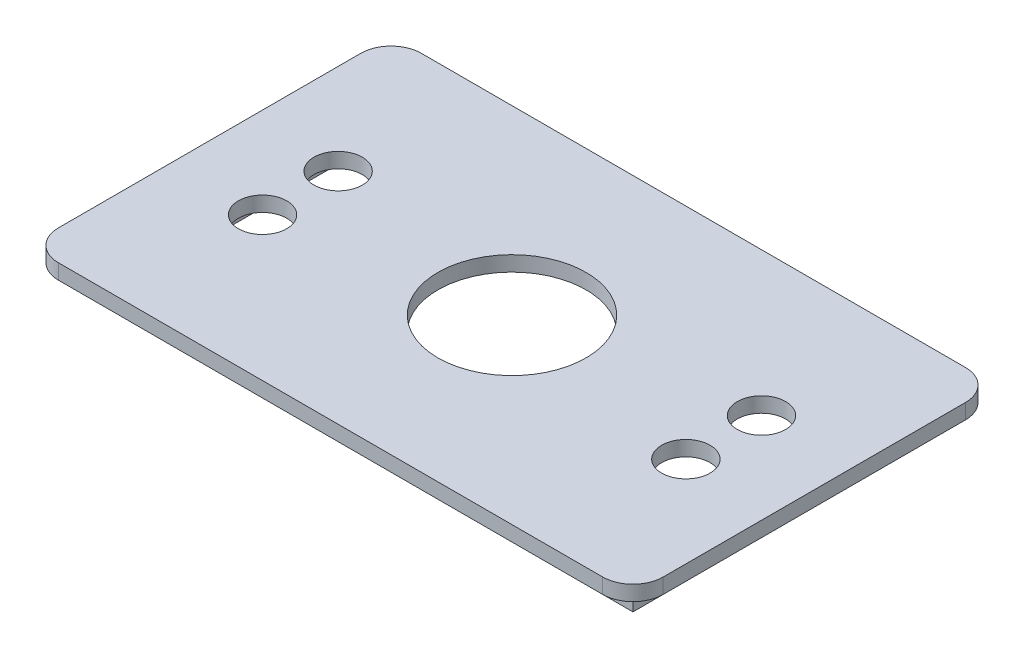
from build123d import *

# Parameters (mm, degrees)
SKETCH1_R           = 24.5
SKETCH1_R_2         = 8
BOSS_EXTRUDE1_DEPTH = 5
SKETCH2_W           = 180
SKETCH2_H           = 100
SKETCH2_W_2         = 174
SKETCH2_H_2         = 94
BOSS_EXTRUDE2_DEPTH = 10


with BuildPart() as part:
    # Sketch1 → Boss-Extrude1 (new body)
    with BuildSketch(Plane(origin=(0, 0, 0), x_dir=(1, 0, 0), z_dir=(0, 1, 0))):
        with BuildLine():
            Line((-90, 60), (90, 60))
            ThreePointArc((90, 60), (97.071067812, 57.071067812), (100, 50))
            Line((100, 50), (100, -50))
            ThreePointArc((100, -50), (97.071067812, -57.071067812), (90, -60))
            Line((90, -60), (-90, -60))
            ThreePointArc((-90, -60), (-97.071067812, -57.071067812), (-100, -50))
            Line((-100, -50), (-100, 50))
            ThreePointArc((-100, 50), (-97.071067812, 57.071067812), (-90, 60))
        make_face()
        Circle(SKETCH1_R, mode=Mode.SUBTRACT)
        with Locations((-70, 12.5)):
            Circle(SKETCH1_R_2, mode=Mode.SUBTRACT)
        with Locations((-70, -12.5)):
            Circle(SKETCH1_R_2, mode=Mode.SUBTRACT)
        with Locations((70, 12.5)):
            Circle(SKETCH1_R_2, mode=Mode.SUBTRACT)
        with Locations((70, -12.5)):
            Circle(SKETCH1_R_2, mode=Mode.SUBTRACT)
    extrude(amount=BOSS_EXTRUDE1_DEPTH)

    # Sketch2 → Boss-Extrude2 (add)
    with BuildSketch(Plane.XZ):
        Rectangle(SKETCH2_W, SKETCH2_H)
        Rectangle(SKETCH2_W_2, SKETCH2_H_2, mode=Mode.SUBTRACT)
    extrude(amount=BOSS_EXTRUDE2_DEPTH)


solid = part.part
